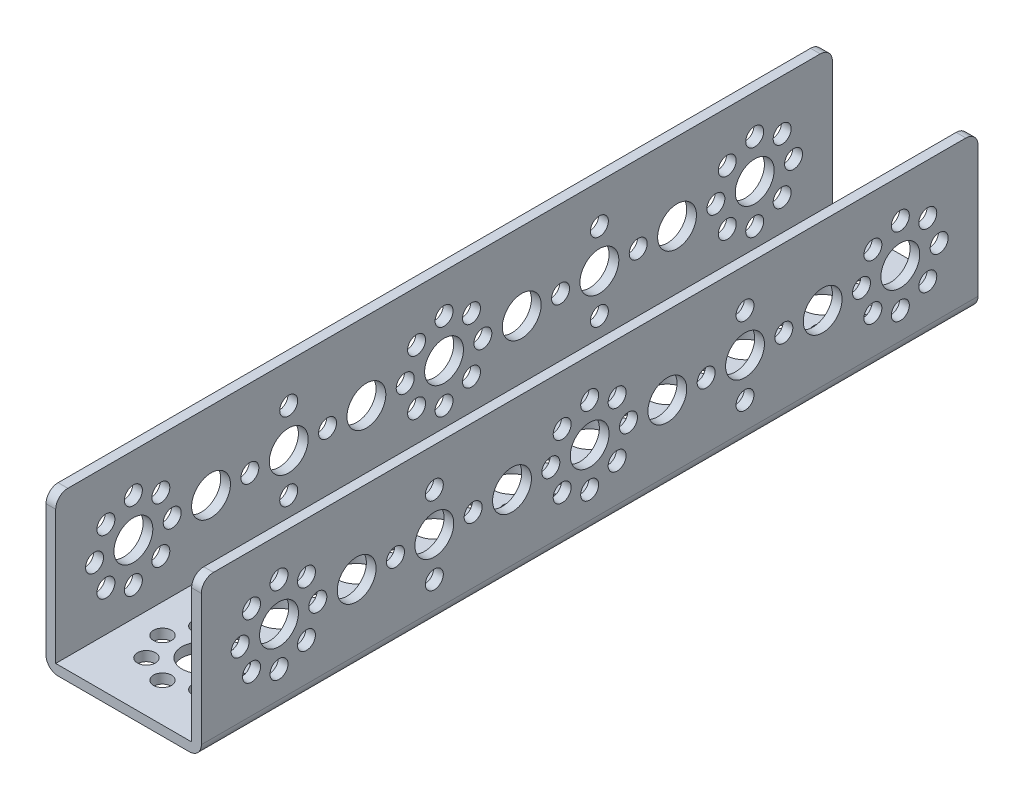
from build123d import *

# Parameters (mm, degrees)
SKETCH1_W                      = 160
SKETCH1_H                      = 32
BOSS_EXTRUDE1_DEPTH            = 32
SKETCH2_W                      = 28
SKETCH2_H                      = 30
CUT_EXTRUDE1_DEPTH             = 161
F_8_0_8_DIAMETER_HOLE1_D       = 8
F_8_0_8_DIAMETER_HOLE1_DEPTH   = 2
F_3_7_3_7_DIAMETER_HOLE1_D     = 3.7
F_3_7_3_7_DIAMETER_HOLE1_DEPTH = 2
F_3_7_3_7_DIAMETER_HOLE2_D     = 3.7
F_3_7_3_7_DIAMETER_HOLE2_DEPTH = 32
F_8_0_8_DIAMETER_HOLE2_D       = 8
F_8_0_8_DIAMETER_HOLE2_DEPTH   = 32
F_8_0_8_DIAMETER_HOLE3_D       = 8
F_8_0_8_DIAMETER_HOLE3_DEPTH   = 2
F_8_0_8_DIAMETER_HOLE4_D       = 8
F_8_0_8_DIAMETER_HOLE4_DEPTH   = 32
F_3_7_3_7_DIAMETER_HOLE3_D     = 3.7
F_3_7_3_7_DIAMETER_HOLE3_DEPTH = 32
FILLET1_R                      = 2.5


with BuildPart() as part:
    # Sketch1 → Boss-Extrude1 (new body)
    with BuildSketch(Plane(origin=(16, 0, 0), x_dir=(0, 0, -1), z_dir=(1, 0, 0))):
        with Locations((64, 16)):
            Rectangle(SKETCH1_W, SKETCH1_H)
    extrude(amount=-BOSS_EXTRUDE1_DEPTH)

    # Sketch2 → Cut-Extrude1 (cut, through all)
    with BuildSketch(Plane(origin=(0, 0, -144), x_dir=(-1, 0, 0), z_dir=(0, 0, -1))):
        with Locations((0, 17)):
            Rectangle(SKETCH2_W, SKETCH2_H)
    extrude(amount=-CUT_EXTRUDE1_DEPTH, mode=Mode.SUBTRACT)

    # Ø8.0 (8) Diameter Hole1
    with Locations(Plane.ZY.offset(16)):
        with Locations((-64, 16), (-128, 16), (-32, 16), (-96, 16), (-16, 16), (-48, 16), (-80, 16), (-112, 16), (0, 16)):
            Hole(F_8_0_8_DIAMETER_HOLE1_D / 2, depth=F_8_0_8_DIAMETER_HOLE1_DEPTH)

    # Ø3.7 (3.7) Diameter Hole1
    with Locations(Plane.ZY.offset(16)):
        with Locations((0, 24), (0, 8), (-8, 16), (8, 16), (-5.656854249, 21.656854249), (5.656854249, 21.656854249), (5.656854249, 10.343145751), (-5.656854249, 10.343145751), (-64, 24), (-64, 8), (-72, 16), (-56, 16), (-69.656854249, 21.656854249), (-58.343145751, 21.656854249), (-58.343145751, 10.343145751), (-69.656854249, 10.343145751), (-128, 24), (-128, 8), (-136, 16), (-120, 16), (-133.656854249, 21.656854249), (-122.34314575, 21.656854249), (-122.34314575, 10.343145751), (-133.656854249, 10.343145751), (-32, 24), (-40, 16), (-32, 8), (-24, 16), (-96, 24), (-104, 16), (-96, 8), (-88, 16)):
            Hole(F_3_7_3_7_DIAMETER_HOLE1_D / 2, depth=F_3_7_3_7_DIAMETER_HOLE1_DEPTH)

    # Ø3.7 (3.7) Diameter Hole2
    with Locations(Plane(origin=(0, 0, 0), x_dir=(-1, 0, 0), z_dir=(0, -1, 0))):
        with Locations((8, 0), (5.656854249, 5.656854249), (0, 8), (-5.656854249, 5.656854249), (-8, 0), (-5.656854249, -5.656854249), (0, -8), (5.656854249, -5.656854249), (8, 64), (5.656854249, 69.656854249), (0, 72), (-5.656854249, 69.656854249), (-8, 64), (-5.656854249, 58.343145751), (0, 56), (5.656854249, 58.343145751), (8, 128), (5.656854249, 133.656854249), (0, 136), (-5.656854249, 133.656854249), (-8, 128), (-5.656854249, 122.34314575), (0, 120), (5.656854249, 122.34314575), (8, 32), (0, 40), (-8, 32), (0, 24), (8, 96), (0, 104), (-8, 96), (0, 88)):
            Hole(F_3_7_3_7_DIAMETER_HOLE2_D / 2, depth=F_3_7_3_7_DIAMETER_HOLE2_DEPTH)

    # Ø8.0 (8) Diameter Hole2
    with Locations(Plane(origin=(0, 0, 0), x_dir=(-1, 0, 0), z_dir=(0, -1, 0))):
        with Locations((0, 0), (0, 64), (0, 128), (0, 32), (0, 96), (0, 16), (0, 48), (0, 80), (0, 112)):
            Hole(F_8_0_8_DIAMETER_HOLE2_D / 2, depth=F_8_0_8_DIAMETER_HOLE2_DEPTH)

    # Ø8.0 (8) Diameter Hole3
    with Locations(Plane.ZY.offset(-14)):
        with Locations((-32, 16)):
            Hole(F_8_0_8_DIAMETER_HOLE3_D / 2, depth=F_8_0_8_DIAMETER_HOLE3_DEPTH)

    # Ø8.0 (8) Diameter Hole4
    with Locations(Plane(origin=(16, 0, 0), x_dir=(0, 0, -1), z_dir=(1, 0, 0))):
        with Locations((64, 16), (128, 16), (96, 16), (16, 16), (48, 16), (80, 16), (112, 16), (0, 16)):
            Hole(F_8_0_8_DIAMETER_HOLE4_D / 2, depth=F_8_0_8_DIAMETER_HOLE4_DEPTH)

    # Ø3.7 (3.7) Diameter Hole3
    with Locations(Plane(origin=(16, 0, 0), x_dir=(0, 0, -1), z_dir=(1, 0, 0))):
        with Locations((0, 24), (0, 8), (8, 16), (-8, 16), (5.656854249, 21.656854249), (-5.656854249, 21.656854249), (-5.656854249, 10.343145751), (5.656854249, 10.343145751), (64, 24), (64, 8), (72, 16), (56, 16), (69.656854249, 21.656854249), (58.343145751, 21.656854249), (58.343145751, 10.343145751), (69.656854249, 10.343145751), (128, 24), (128, 8), (136, 16), (120, 16), (133.656854249, 21.656854249), (122.34314575, 21.656854249), (122.34314575, 10.343145751), (133.656854249, 10.343145751), (32, 24), (40, 16), (32, 8), (24, 16), (96, 24), (104, 16), (96, 8), (88, 16)):
            Hole(F_3_7_3_7_DIAMETER_HOLE3_D / 2, depth=F_3_7_3_7_DIAMETER_HOLE3_DEPTH)

    # Fillet1
    fillet1_edges = [part.edges().sort_by_distance(p)[0] for p in [
        (-16, 0, -64),
        (15, 32, 16),
        (15, 32, -144),
        (16, 0, -64),
        (-15, 32, -144),
        (-15, 32, 16),
    ]]
    fillet(fillet1_edges, radius=FILLET1_R)


solid = part.part
